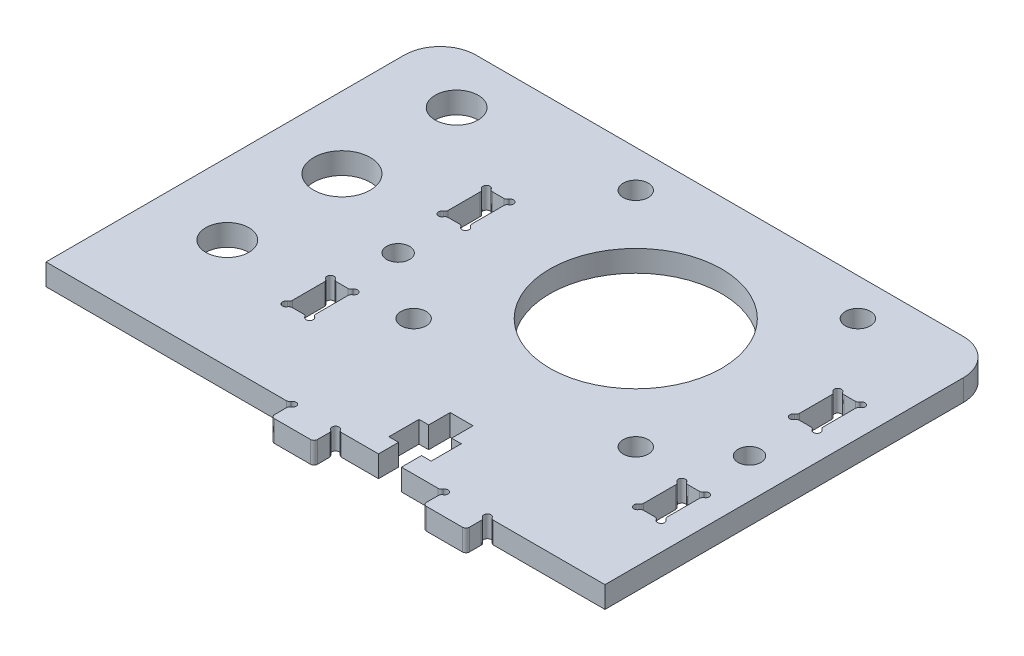
from build123d import *

# Parameters (mm, degrees)
SKETCH1_R           = 1.6
SKETCH1_R_2         = 1.75
SKETCH1_R_3         = 3.95
SKETCH1_R_4         = 12
SKETCH1_R_5         = 3
BOSS_EXTRUDE1_DEPTH = 3


with BuildPart() as part:
    # Sketch1 → Boss-Extrude1 (new body)
    with BuildSketch(Plane(origin=(0, 0, 0), x_dir=(1, 0, 0), z_dir=(0, 1, 0))):
        with BuildLine():
            Line((294.373353, 1022.190294437), (327.907309833, 1022.190294437))
            ThreePointArc((327.907309833, 1022.190294437), (328.157309833, 1022.257281735), (328.340322535, 1022.440294437))
            ThreePointArc((328.340322535, 1022.440294437), (329.126888323, 1022.543848684), (329.023336329, 1021.757282599))
            ThreePointArc((329.023336329, 1021.757282599), (328.840324865, 1021.574270305), (328.773337833, 1021.324271437))
            Line((328.773337833, 1021.324271437), (328.773337833, 1019.690242437))
            ThreePointArc((328.773337833, 1019.690242437), (328.919784442, 1019.336689047), (329.273337833, 1019.190242437))
            Line((329.273337833, 1019.190242437), (334.273335833, 1019.190242437))
            ThreePointArc((334.273335833, 1019.190242437), (334.626889492, 1019.336688397), (334.773336751, 1019.690241519))
            Line((334.773336751, 1019.690241519), (334.773336751, 1021.324268519))
            ThreePointArc((334.773336751, 1021.324268519), (334.706349307, 1021.57426848), (334.523336498, 1021.757281075))
            ThreePointArc((334.523336498, 1021.757281075), (334.419781792, 1022.543846802), (335.206347937, 1022.440295269))
            ThreePointArc((335.206347937, 1022.440295269), (335.389360338, 1022.257283911), (335.639359245, 1022.190297025))
            Line((335.639359245, 1022.190297025), (340.773337745, 1022.190297025))
            Line((340.773337745, 1022.190297025), (340.773337745, 1024.990297025))
            Line((340.773337745, 1024.990297025), (339.423337745, 1024.990297025))
            Line((339.423337745, 1024.990297025), (339.423337745, 1029.190297025))
            Line((339.423337745, 1029.190297025), (340.773337745, 1029.190297025))
            Line((340.773337745, 1029.190297025), (340.773337745, 1032.190297025))
            Line((340.773337745, 1032.190297025), (343.973337745, 1032.190297025))
            Line((343.973337745, 1032.190297025), (343.973337745, 1029.190297025))
            Line((343.973337745, 1029.190297025), (345.323337745, 1029.190297025))
            Line((345.323337745, 1029.190297025), (345.323337745, 1024.990292188))
            Line((345.323337745, 1024.990292188), (343.973337745, 1024.990292188))
            Line((343.973337745, 1024.990292188), (343.973337745, 1022.190292188))
            Line((343.973337745, 1022.190292188), (349.107314245, 1022.190292188))
            ThreePointArc((349.107314245, 1022.190292188), (349.357314245, 1022.257279486), (349.540326947, 1022.440292188))
            ThreePointArc((349.540326947, 1022.440292188), (350.326891976, 1022.543845827), (350.223341741, 1021.75728035))
            ThreePointArc((350.223341741, 1021.75728035), (350.040330277, 1021.574268055), (349.973343245, 1021.324269188))
            Line((349.973343245, 1021.324269188), (349.973343245, 1019.690240188))
            ThreePointArc((349.973343245, 1019.690240188), (350.119789854, 1019.336686797), (350.473343245, 1019.190240188))
            Line((350.473343245, 1019.190240188), (355.473340245, 1019.190240188))
            ThreePointArc((355.473340245, 1019.190240188), (355.826893904, 1019.336686148), (355.973341163, 1019.69023927))
            Line((355.973341163, 1019.69023927), (355.973341163, 1021.32426627))
            ThreePointArc((355.973341163, 1021.32426627), (355.906353816, 1021.574266257), (355.723341079, 1021.757278924))
            ThreePointArc((355.723341079, 1021.757278924), (355.619786681, 1022.543844692), (356.406352785, 1022.44029285))
            ThreePointArc((356.406352785, 1022.44029285), (356.589365364, 1022.257281277), (356.839364571, 1022.190294437))
            Line((356.839364571, 1022.190294437), (372.373340046, 1022.190294437))
            Line((372.373340046, 1022.190294437), (372.373340046, 1072.190301225))
            ThreePointArc((372.373340046, 1072.190301225), (370.908873244, 1075.725833838), (367.373340046, 1077.190299225))
            Line((367.373340046, 1077.190299225), (299.37334805, 1077.190299225))
            ThreePointArc((299.37334805, 1077.190299225), (295.837816019, 1075.725834155), (294.373353, 1072.190301275))
            Line((294.373353, 1072.190301275), (294.373353, 1022.190294437))
        make_face()
        with Locations((366.893344996, 1047.842461747)):
            Circle(SKETCH1_R, mode=Mode.SUBTRACT)
        with Locations((357.873345496, 1071.990299275)):
            Circle(SKETCH1_R_2, mode=Mode.SUBTRACT)
        with Locations((357.873345496, 1040.990299275)):
            Circle(SKETCH1_R_2, mode=Mode.SUBTRACT)
        with Locations((304.373346, 1053.49029927)):
            Circle(SKETCH1_R_3, mode=Mode.SUBTRACT)
        with Locations((342.373345496, 1056.490299275)):
            Circle(SKETCH1_R_4, mode=Mode.SUBTRACT)
        with Locations((326.873345496, 1071.990299275)):
            Circle(SKETCH1_R_2, mode=Mode.SUBTRACT)
        with Locations((326.873345496, 1040.990299275)):
            Circle(SKETCH1_R_2, mode=Mode.SUBTRACT)
        with Locations((317.853347996, 1047.84952041)):
            Circle(SKETCH1_R, mode=Mode.SUBTRACT)
        with Locations((304.373346, 1069.49029927)):
            Circle(SKETCH1_R_5, mode=Mode.SUBTRACT)
        with Locations((304.373346, 1037.49029927)):
            Circle(SKETCH1_R_5, mode=Mode.SUBTRACT)
        with BuildLine():
            Line((365.243389653, 1060.95296097), (365.243389653, 1056.48501097))
            ThreePointArc((365.243389653, 1056.48501097), (365.176400533, 1056.235010504), (364.993385671, 1056.051998658))
            ThreePointArc((364.993385671, 1056.051998658), (364.889836092, 1055.26543287), (365.676401176, 1055.368987799))
            ThreePointArc((365.676401176, 1055.368987799), (365.859413353, 1055.55200075), (366.109412996, 1055.618988627))
            Line((366.109412996, 1055.618988627), (367.677282996, 1055.618988627))
            ThreePointArc((367.677282996, 1055.618988627), (367.927282247, 1055.552001761), (368.110294834, 1055.368990124))
            ThreePointArc((368.110294834, 1055.368990124), (368.896860423, 1055.26543905), (368.793306996, 1056.052004329))
            ThreePointArc((368.793306996, 1056.052004329), (368.610294145, 1056.235017289), (368.543306996, 1056.485017627))
            Line((368.543306996, 1056.485017627), (368.543306996, 1060.952967627))
            ThreePointArc((368.543306996, 1060.952967627), (368.610293862, 1061.202966879), (368.793305499, 1061.385979465))
            ThreePointArc((368.793305499, 1061.385979465), (368.89685718, 1062.172545813), (368.110291294, 1062.068990627))
            ThreePointArc((368.110291294, 1062.068990627), (367.927278767, 1061.885978026), (367.677278996, 1061.818990627))
            Line((367.677278996, 1061.818990627), (366.109410996, 1061.818990627))
            ThreePointArc((366.109410996, 1061.818990627), (365.859411616, 1061.885977015), (365.676398679, 1062.068988302))
            ThreePointArc((365.676398679, 1062.068988302), (364.889832133, 1062.172538478), (364.993388824, 1061.38597279))
            ThreePointArc((364.993388824, 1061.38597279), (365.176401775, 1061.202960613), (365.243389653, 1060.95296097))
        make_face(mode=Mode.SUBTRACT)
        with BuildLine():
            Line((318.637281496, 1061.818997965), (317.069414496, 1061.818997965))
            ThreePointArc((317.069414496, 1061.818997965), (316.819415116, 1061.885984352), (316.636402179, 1062.06899564))
            ThreePointArc((316.636402179, 1062.06899564), (315.849836392, 1062.172545208), (315.953391324, 1061.385980127))
            ThreePointArc((315.953391324, 1061.385980127), (316.136404615, 1061.202967361), (316.203392153, 1060.952966947))
            Line((316.203392153, 1060.952966947), (316.203392153, 1056.485018307))
            ThreePointArc((316.203392153, 1056.485018307), (316.136403033, 1056.235017841), (315.953388171, 1056.052005995))
            ThreePointArc((315.953388171, 1056.052005995), (315.849838592, 1055.265440207), (316.636403676, 1055.368995136))
            ThreePointArc((316.636403676, 1055.368995136), (316.819416286, 1055.552008337), (317.069416496, 1055.618995965))
            Line((317.069416496, 1055.618995965), (318.637286496, 1055.618995965))
            ThreePointArc((318.637286496, 1055.618995965), (318.887285747, 1055.552009098), (319.070298334, 1055.368997461))
            ThreePointArc((319.070298334, 1055.368997461), (319.856863923, 1055.265446387), (319.753310496, 1056.052011666))
            ThreePointArc((319.753310496, 1056.052011666), (319.570297645, 1056.235024626), (319.503310496, 1056.485024964))
            Line((319.503310496, 1056.485024964), (319.503310496, 1060.952974964))
            ThreePointArc((319.503310496, 1060.952974964), (319.570297362, 1061.202974216), (319.753308999, 1061.385986802))
            ThreePointArc((319.753308999, 1061.385986802), (319.85686068, 1062.17255315), (319.070294794, 1062.068997964))
            ThreePointArc((319.070294794, 1062.068997964), (318.887281834, 1061.885985114), (318.637281496, 1061.818997965))
        make_face(mode=Mode.SUBTRACT)
        with BuildLine():
            Line((316.203388653, 1039.193570463), (316.203388653, 1034.725621463))
            ThreePointArc((316.203388653, 1034.725621463), (316.136399531, 1034.475620993), (315.953384663, 1034.292609147))
            ThreePointArc((315.953384663, 1034.292609147), (315.849835095, 1033.506043359), (316.636400176, 1033.609598291))
            ThreePointArc((316.636400176, 1033.609598291), (316.819412786, 1033.792611493), (317.069412996, 1033.85959912))
            Line((317.069412996, 1033.85959912), (318.637282996, 1033.85959912))
            ThreePointArc((318.637282996, 1033.85959912), (318.887282247, 1033.792612254), (319.070294834, 1033.609600616))
            ThreePointArc((319.070294834, 1033.609600616), (319.856860423, 1033.506049543), (319.753306996, 1034.292614822))
            ThreePointArc((319.753306996, 1034.292614822), (319.570294395, 1034.475627349), (319.503306996, 1034.72562712))
            Line((319.503306996, 1034.72562712), (319.503306996, 1039.19357712))
            ThreePointArc((319.503306996, 1039.19357712), (319.570293862, 1039.443576372), (319.753305499, 1039.626588958))
            ThreePointArc((319.753305499, 1039.626588958), (319.856856573, 1040.413154547), (319.070291294, 1040.30960112))
            ThreePointArc((319.070291294, 1040.30960112), (318.887278334, 1040.126588269), (318.637277996, 1040.05960112))
            Line((318.637277996, 1040.05960112), (317.069410996, 1040.05960112))
            ThreePointArc((317.069410996, 1040.05960112), (316.819411616, 1040.126587508), (316.636398679, 1040.309598795))
            ThreePointArc((316.636398679, 1040.309598795), (315.849832892, 1040.413148364), (315.953387824, 1039.626583283))
            ThreePointArc((315.953387824, 1039.626583283), (316.136401025, 1039.443570673), (316.203388653, 1039.193570463))
        make_face(mode=Mode.SUBTRACT)
        with BuildLine():
            Line((368.543303996, 1034.72562712), (368.543303996, 1039.19357712))
            ThreePointArc((368.543303996, 1039.19357712), (368.610290862, 1039.443576372), (368.793302499, 1039.626588958))
            ThreePointArc((368.793302499, 1039.626588958), (368.896853573, 1040.413154547), (368.110288294, 1040.30960112))
            ThreePointArc((368.110288294, 1040.30960112), (367.927275767, 1040.126588519), (367.677275996, 1040.05960112))
            Line((367.677275996, 1040.05960112), (366.109407996, 1040.05960112))
            ThreePointArc((366.109407996, 1040.05960112), (365.859408616, 1040.126587508), (365.676395679, 1040.309598795))
            ThreePointArc((365.676395679, 1040.309598795), (364.889829133, 1040.413148971), (364.993385824, 1039.626583283))
            ThreePointArc((364.993385824, 1039.626583283), (365.176399025, 1039.443570673), (365.243386653, 1039.193570463))
            Line((365.243386653, 1039.193570463), (365.243386653, 1034.725621463))
            ThreePointArc((365.243386653, 1034.725621463), (365.176397531, 1034.475620993), (364.993382663, 1034.292609147))
            ThreePointArc((364.993382663, 1034.292609147), (364.889833095, 1033.506043359), (365.676398176, 1033.609598291))
            ThreePointArc((365.676398176, 1033.609598291), (365.859410353, 1033.792611243), (366.109409996, 1033.85959912))
            Line((366.109409996, 1033.85959912), (367.677279996, 1033.85959912))
            ThreePointArc((367.677279996, 1033.85959912), (367.927279247, 1033.792612254), (368.110291834, 1033.609600616))
            ThreePointArc((368.110291834, 1033.609600616), (368.896857423, 1033.506049543), (368.793303996, 1034.292614822))
            ThreePointArc((368.793303996, 1034.292614822), (368.610291395, 1034.475627349), (368.543303996, 1034.72562712))
        make_face(mode=Mode.SUBTRACT)
    extrude(amount=BOSS_EXTRUDE1_DEPTH)


solid = part.part
